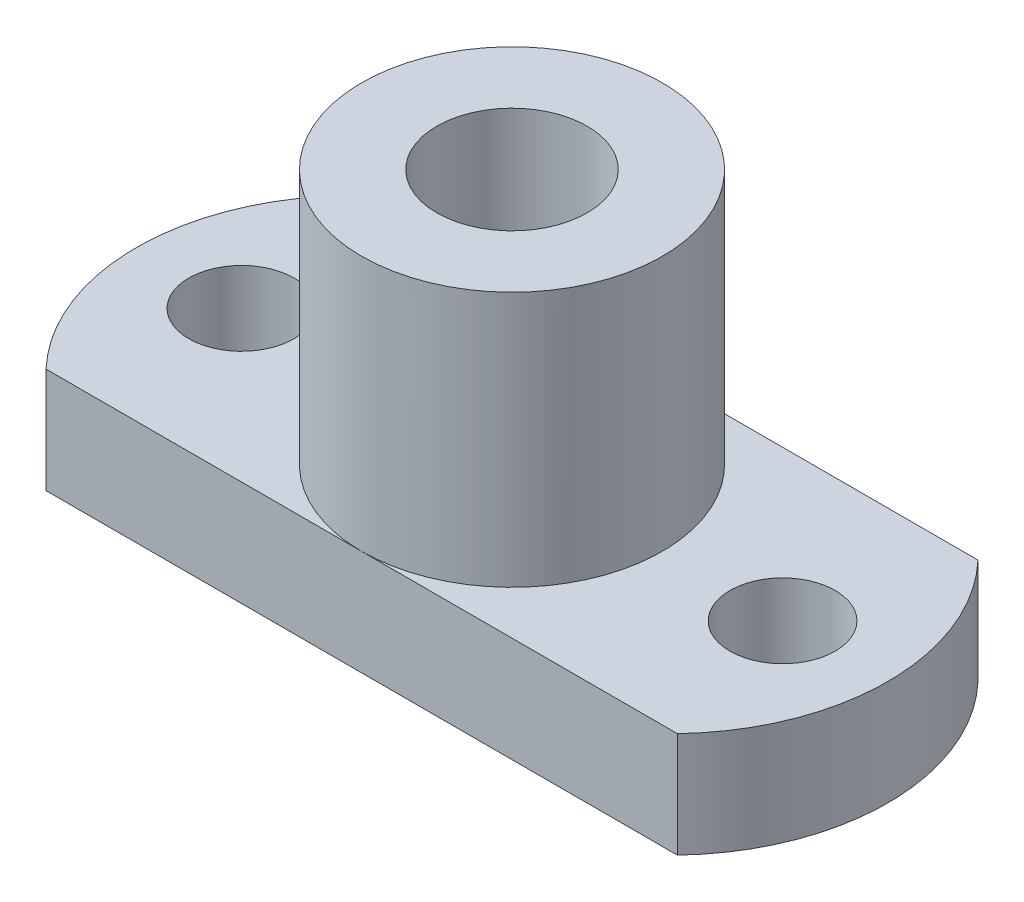
from build123d import *

# Parameters (mm, degrees)
SKETCH1_R           = 5
SKETCH1_R_2         = 2.5
BOSS_EXTRUDE1_DEPTH = 12
SKETCH2_R           = 1.75
BOSS_EXTRUDE2_DEPTH = 3.5


with BuildPart() as part:
    # Sketch1 → Boss-Extrude1 (new body)
    with BuildSketch(Plane(origin=(0, 0, 0), x_dir=(1, 0, 0), z_dir=(0, 1, 0))):
        Circle(SKETCH1_R)
        Circle(SKETCH1_R_2, mode=Mode.SUBTRACT)
    extrude(amount=BOSS_EXTRUDE1_DEPTH)

    # Sketch2 → Boss-Extrude2 (add)
    with BuildSketch(Plane(origin=(0, 0, 0), x_dir=(1, 0, 0), z_dir=(0, 1, 0))):
        with BuildLine():
            Line((0, -5), (-10.5, -5))
            ThreePointArc((-10.5, -5), (-12.5, 0), (-10.5, 5))
            Line((-10.5, 5), (0, 5))
            ThreePointArc((0, 5), (-5, 0), (0, -5))
        make_face()
        with Locations((-9, 0)):
            Circle(SKETCH2_R, mode=Mode.SUBTRACT)
    boss_extrude2 = extrude(amount=BOSS_EXTRUDE2_DEPTH)

    # Mirror1: Boss-Extrude2 across plane
    add(boss_extrude2.mirror(Plane(origin=(0, 0, 0), x_dir=(0, 0, 1), z_dir=(1, 0, 0))))


solid = part.part
